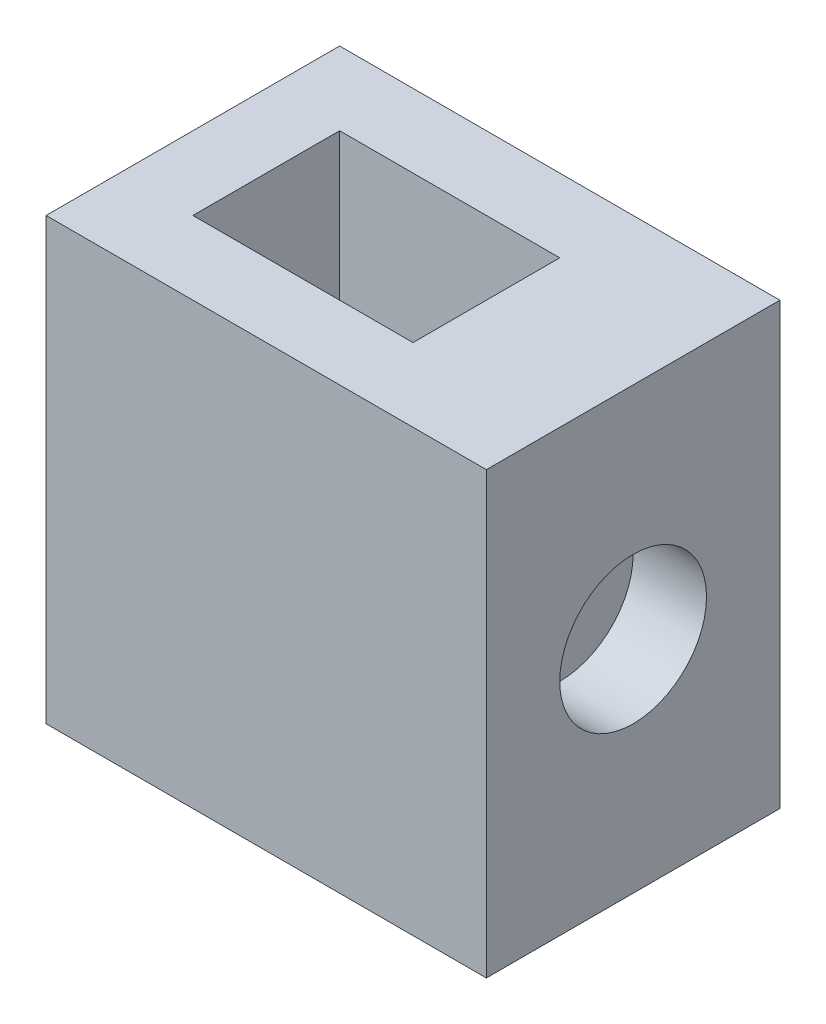
from build123d import *

# Parameters (mm, degrees)
SKETCH1_W           = 76.2
SKETCH1_H           = 50.8
BOSS_EXTRUDE1_DEPTH = 76.2
SKETCH2_W           = 38.1
SKETCH2_H           = 25.4
CUT_EXTRUDE1_DEPTH  = 25.4
SKETCH3_R           = 12.7
CUT_EXTRUDE3_DEPTH  = 12.7


with BuildPart() as part:
    # Sketch1 → Boss-Extrude1 (new body)
    with BuildSketch(Plane(origin=(0, 0, 0), x_dir=(1, 0, 0), z_dir=(0, 1, 0))):
        with Locations((38.1, 25.4)):
            Rectangle(SKETCH1_W, SKETCH1_H)
    extrude(amount=BOSS_EXTRUDE1_DEPTH)

    # Sketch2 → Cut-Extrude1 (cut)
    with BuildSketch(Plane(origin=(0, 76.2, 0), x_dir=(1, 0, 0), z_dir=(0, 1, 0))):
        with Locations((31.75, 25.4)):
            Rectangle(SKETCH2_W, SKETCH2_H)
    extrude(amount=-CUT_EXTRUDE1_DEPTH, mode=Mode.SUBTRACT)

    # Sketch3 → Cut-Extrude3 (cut)
    with BuildSketch(Plane(origin=(76.2, 0, 0), x_dir=(0, 0, -1), z_dir=(1, 0, 0))):
        with Locations((25.4, 38.1)):
            Circle(SKETCH3_R)
    extrude(amount=-CUT_EXTRUDE3_DEPTH, mode=Mode.SUBTRACT)


solid = part.part
